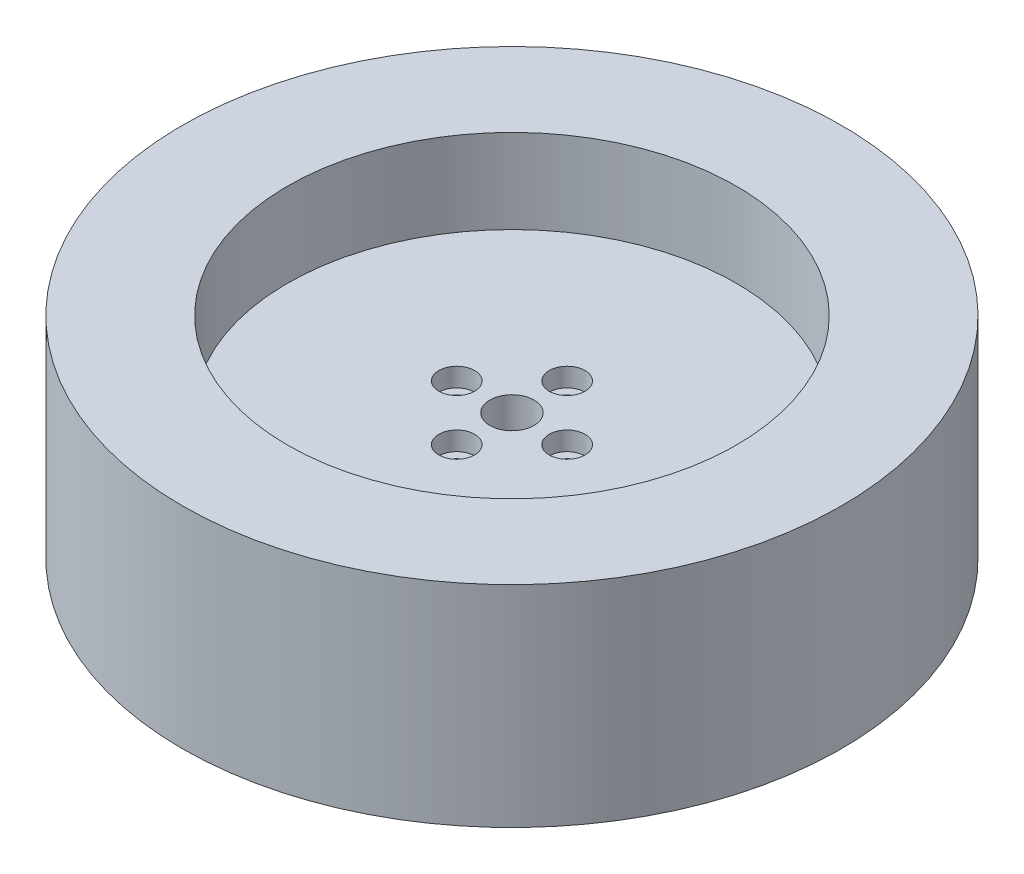
from build123d import *

# Parameters (mm, degrees)
BOSS_EXTRUDE1_DEPTH                                 = 19.05
BOSS_EXTRUDE1_DEPTH_BACK                            = 19.05
SKETCH1_R                                           = 59.69
SKETCH2_R                                           = 40.64
CUT_EXTRUDE2_DEPTH                                  = 15.24
CUT_EXTRUDE7_START                                  = -15.24
SKETCH13_R                                          = 40.64
CUT_EXTRUDE7_DEPTH                                  = 15.24
SKETCH7_R                                           = 4
CUT_EXTRUDE6_DEPTH                                  = 25
SKETCH6_R                                           = 1.7
CUT_EXTRUDE5_DEPTH                                  = 10
CIRPATTERN2_COUNT                                   = 4
CBORE_FOR_M3_HEX_SOCKET_HEAD_CAP_SCREW1_D           = 3.4
CBORE_FOR_M3_HEX_SOCKET_HEAD_CAP_SCREW1_DEPTH       = 5
CBORE_FOR_M3_HEX_SOCKET_HEAD_CAP_SCREW1_CBORE_D     = 6.5
CBORE_FOR_M3_HEX_SOCKET_HEAD_CAP_SCREW1_CBORE_DEPTH = 3.4
CBORE_FOR_M3_HEX_SOCKET_HEAD_CAP_SCREW1_TIP         = 1.021463052
SKETCH14_R                                          = 15
CUT_EXTRUDE8_DEPTH                                  = 2


with BuildPart() as part:
    # Sketch1 → Boss-Extrude1 (new, two sides: drawn at the far end of the back side and taken through both)
    with BuildSketch(Plane(origin=(0, 0, 0), x_dir=(1, 0, 0), z_dir=(0, 1, 0)).offset(-BOSS_EXTRUDE1_DEPTH_BACK)):
        Circle(SKETCH1_R)
    extrude(amount=BOSS_EXTRUDE1_DEPTH + BOSS_EXTRUDE1_DEPTH_BACK)

    # Sketch2 → Cut-Extrude2 (cut)
    with BuildSketch(Plane.XZ.offset(19.05)):
        Circle(SKETCH2_R)
    extrude(amount=-CUT_EXTRUDE2_DEPTH, mode=Mode.SUBTRACT)

    # Sketch13 → Cut-Extrude7 (cut)
    with BuildSketch(Plane(origin=(0, 19.05, 0), x_dir=(1, 0, 0), z_dir=(0, 1, 0)).offset(CUT_EXTRUDE7_START)):
        Circle(SKETCH13_R)
    extrude(amount=CUT_EXTRUDE7_DEPTH, mode=Mode.SUBTRACT)

    # Sketch7 → Cut-Extrude6 (cut)
    with BuildSketch(Plane(origin=(0, 3.81, 0), x_dir=(1, 0, 0), z_dir=(0, 1, 0))):
        Circle(SKETCH7_R)
    cut_extrude6 = extrude(amount=-CUT_EXTRUDE6_DEPTH, mode=Mode.SUBTRACT)

    # Sketch6 → Cut-Extrude5 (cut)
    with BuildSketch(Plane(origin=(0, 3.81, 0), x_dir=(1, 0, 0), z_dir=(0, 1, 0))):
        with Locations((0, -10)):
            Circle(SKETCH6_R)
    cut_extrude5 = extrude(amount=-CUT_EXTRUDE5_DEPTH, mode=Mode.SUBTRACT)

    # CirPattern2: Cut-Extrude6, Cut-Extrude5 ×4 about axis
    cirpattern2_axis = Axis((0, 3.81, 0), (0, 1, 0))
    add([cut_extrude6.rotate(cirpattern2_axis, i * 360 / CIRPATTERN2_COUNT) for i in range(1, CIRPATTERN2_COUNT)], mode=Mode.SUBTRACT)
    add([cut_extrude5.rotate(cirpattern2_axis, i * 360 / CIRPATTERN2_COUNT) for i in range(1, CIRPATTERN2_COUNT)], mode=Mode.SUBTRACT)

    # CBORE for M3 Hex Socket Head Cap Screw1
    with Locations(Plane(origin=(0, 3.81, 0), x_dir=(1, 0, 0), z_dir=(0, 1, 0))):
        with Locations((0, -10), (10, 0), (0, 10), (-10, 0)):
            CounterBoreHole(CBORE_FOR_M3_HEX_SOCKET_HEAD_CAP_SCREW1_D / 2, CBORE_FOR_M3_HEX_SOCKET_HEAD_CAP_SCREW1_CBORE_D / 2, CBORE_FOR_M3_HEX_SOCKET_HEAD_CAP_SCREW1_CBORE_DEPTH, depth=CBORE_FOR_M3_HEX_SOCKET_HEAD_CAP_SCREW1_DEPTH)
            with Locations((0, 0, -(CBORE_FOR_M3_HEX_SOCKET_HEAD_CAP_SCREW1_DEPTH + CBORE_FOR_M3_HEX_SOCKET_HEAD_CAP_SCREW1_TIP / 2))):  # 118° drill point
                Cone(0, CBORE_FOR_M3_HEX_SOCKET_HEAD_CAP_SCREW1_D / 2, CBORE_FOR_M3_HEX_SOCKET_HEAD_CAP_SCREW1_TIP, mode=Mode.SUBTRACT)

    # Sketch14 → Cut-Extrude8 (cut)
    with BuildSketch(Plane.XZ.offset(3.81)):
        Circle(SKETCH14_R)
    extrude(amount=-CUT_EXTRUDE8_DEPTH, mode=Mode.SUBTRACT)


solid = part.part
